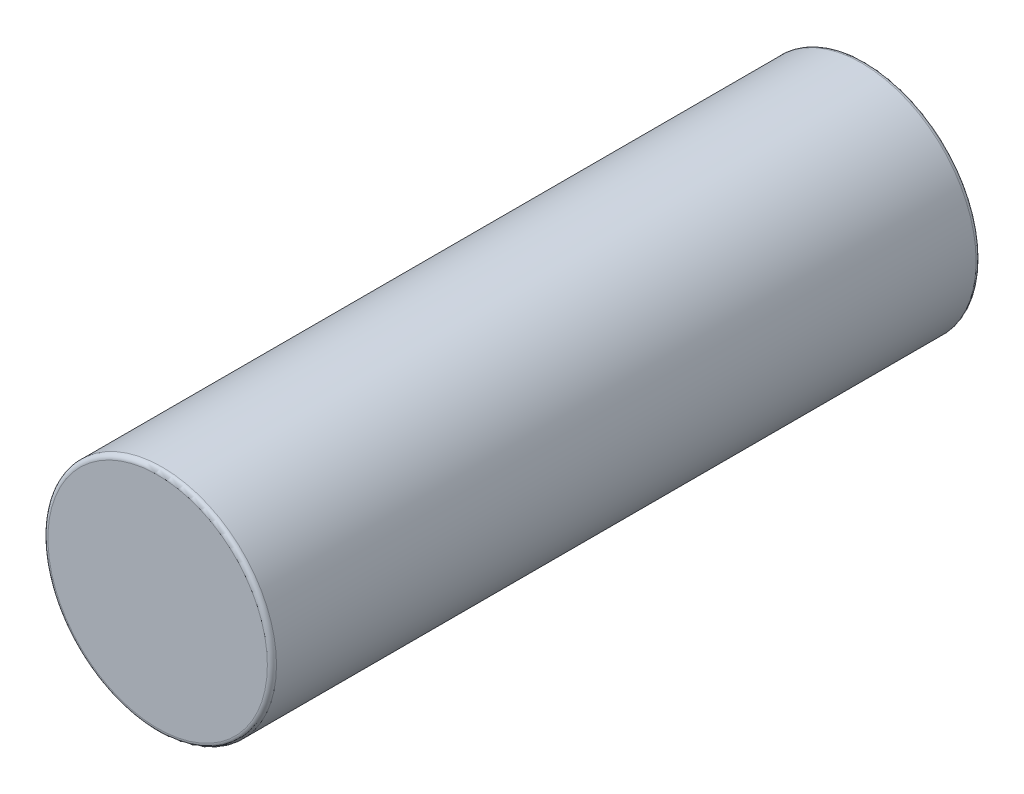
from build123d import *

# Parameters (mm, degrees)
CYCL_DEPTH      = 15.5
CYCL_DEPTH_BACK = 15.5
DIA_R           = 5
FILLET1_R       = 0.2


with BuildPart() as part:
    # dia → cycl (new, two sides: drawn at the far end of the back side and taken through both)
    with BuildSketch(Plane.XY.offset(-CYCL_DEPTH_BACK)):
        Circle(DIA_R)
    extrude(amount=CYCL_DEPTH + CYCL_DEPTH_BACK)

    # Fillet1
    fillet1_edges = [part.edges().sort_by_distance(p)[0] for p in [
        (-5, 0, 15.5),
        (-5, 0, -15.5),
    ]]
    fillet(fillet1_edges, radius=FILLET1_R)


solid = part.part
